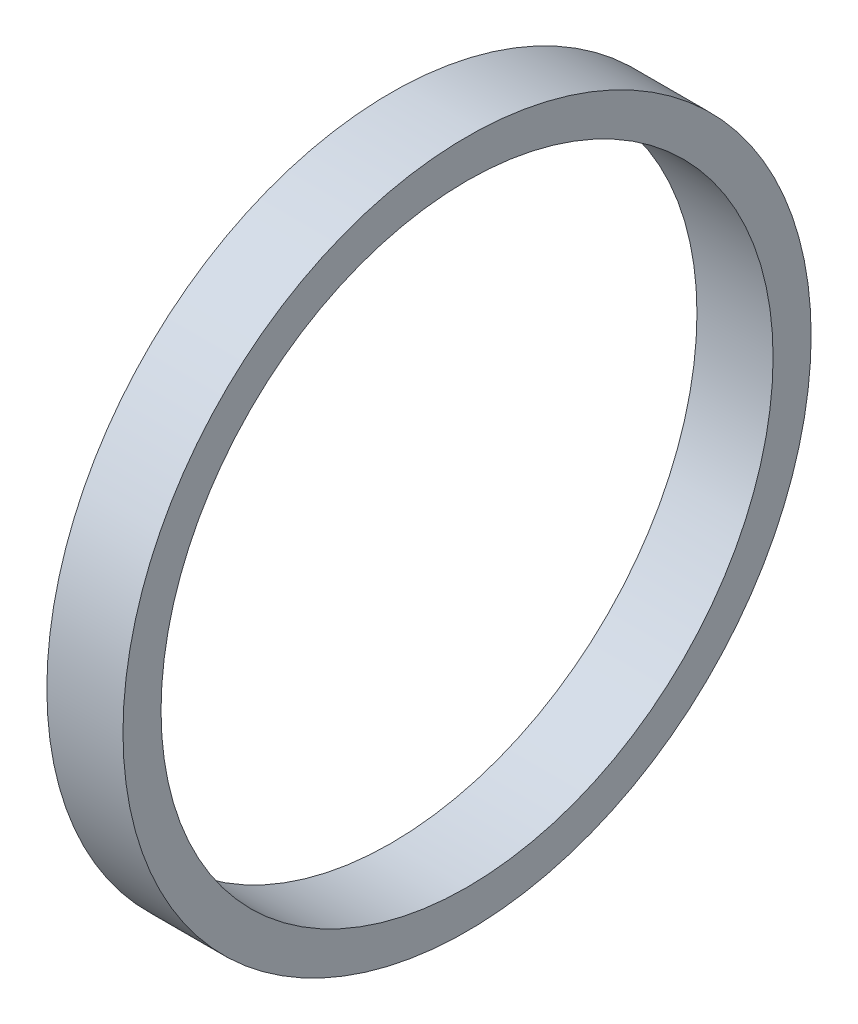
from build123d import *

# Parameters (mm, degrees)
SKETCH1_R           = 57.404
SKETCH1_R_2         = 51.054
BOSS_EXTRUDE1_DEPTH = 6.35


with BuildPart() as part:
    # Sketch1 → Boss-Extrude1 (new body, symmetric)
    with BuildSketch(Plane(origin=(0, 0, 0), x_dir=(0, 0, -1), z_dir=(1, 0, 0))):
        Circle(SKETCH1_R)
        Circle(SKETCH1_R_2, mode=Mode.SUBTRACT)
    extrude(amount=BOSS_EXTRUDE1_DEPTH, both=True)


solid = part.part
